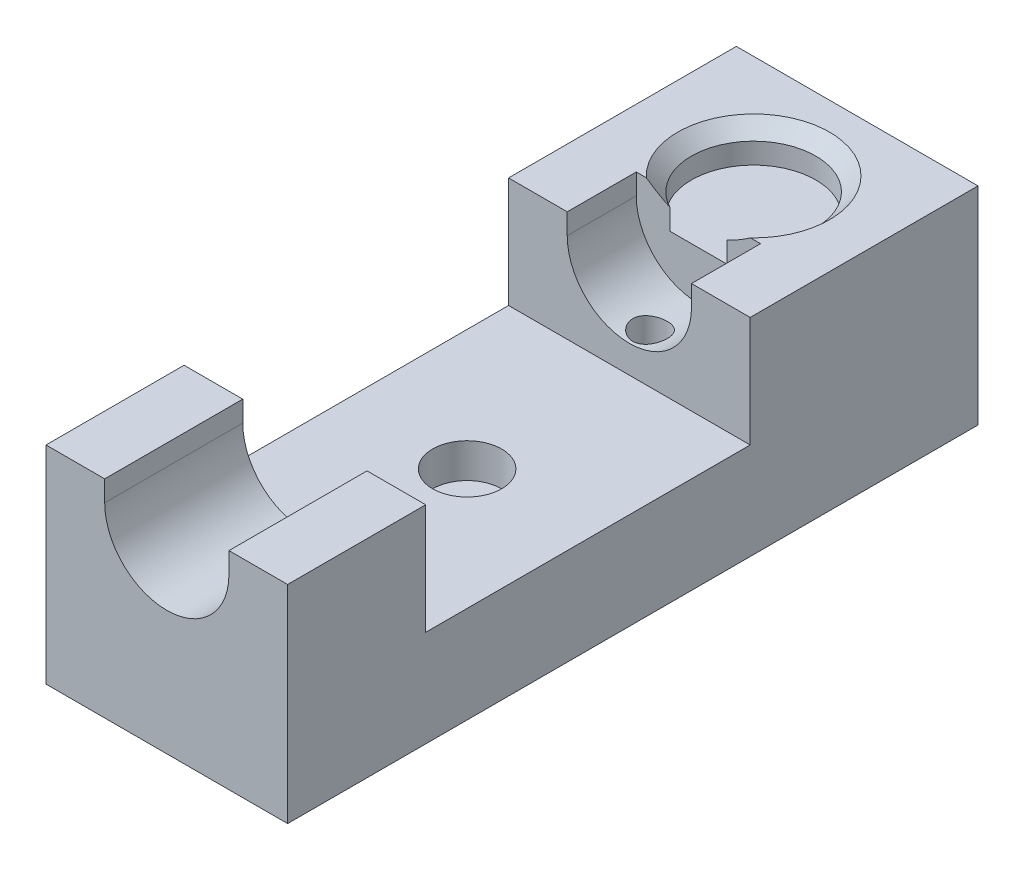
from build123d import *

# Parameters (mm, degrees)
SKETCH_1_W          = 35
SKETCH_1_H          = 100
EXTRUDE_1_DEPTH     = 30
SKETCH_2_R          = 9
CUT_EXTRUDE_1_DEPTH = 5
CHAMFER_1_SIZE      = 2
CUT_EXTRUDE_3_DEPTH = 77
SKETCH_4_W          = 35
SKETCH_4_H          = 47
CUT_EXTRUDE_4_DEPTH = 16
HOLE_WIZARD_M6_1_D  = 5
SKETCH_7_R          = 5
CUT_EXTRUDE_5_DEPTH = 5


with BuildPart() as part:
    # 草图1 → 凸台-拉伸1 (new body)
    with BuildSketch(Plane(origin=(0, 0, 0), x_dir=(1, 0, 0), z_dir=(0, 1, 0))):
        Rectangle(SKETCH_1_W, SKETCH_1_H)
    extrude(amount=EXTRUDE_1_DEPTH)

    # 草图2 → 切除-拉伸1 (cut)
    with BuildSketch(Plane(origin=(0, 30, 0), x_dir=(1, 0, 0), z_dir=(0, 1, 0))):
        with Locations((0, 35)):
            Circle(SKETCH_2_R)
    extrude(amount=-CUT_EXTRUDE_1_DEPTH, mode=Mode.SUBTRACT)

    # 倒角1
    chamfer_1_edges = [part.edges().sort_by_distance(p)[0] for p in [
        (-9, 30, -35),
    ]]
    chamfer(chamfer_1_edges, length=CHAMFER_1_SIZE)

    # 草图3 → 切除-拉伸3 (cut)
    with BuildSketch(Plane.XY.offset(50)):
        with BuildLine():
            Line((9, 33), (9, 27))
            ThreePointArc((9, 27), (0, 18), (-9, 27))
            Line((-9, 27), (-9, 33))
            ThreePointArc((-9, 33), (0, 42), (9, 33))
        make_face()
    extrude(amount=-CUT_EXTRUDE_3_DEPTH, mode=Mode.SUBTRACT)

    # 草图4 → 切除-拉伸4 (cut)
    with BuildSketch(Plane(origin=(0, 30, 0), x_dir=(1, 0, 0), z_dir=(0, 1, 0))):
        with Locations((0, -6.5)):
            Rectangle(SKETCH_4_W, SKETCH_4_H)
    extrude(amount=-CUT_EXTRUDE_4_DEPTH, mode=Mode.SUBTRACT)

    # M6 螺纹孔1 (through all)
    with Locations(Plane(origin=(0, 0, -20), x_dir=(0, 0, -1), z_dir=(0, -1, 0))):
        with Locations((0, 0), (-40, 0)):
            Hole(HOLE_WIZARD_M6_1_D / 2)

    # 草图7 → 切除-拉伸5 (cut)
    with BuildSketch(Plane(origin=(0, 14, 0), x_dir=(1, 0, 0), z_dir=(0, 1, 0))):
        with Locations((0, -6.5)):
            Circle(SKETCH_7_R)
    extrude(amount=-CUT_EXTRUDE_5_DEPTH, mode=Mode.SUBTRACT)


solid = part.part
